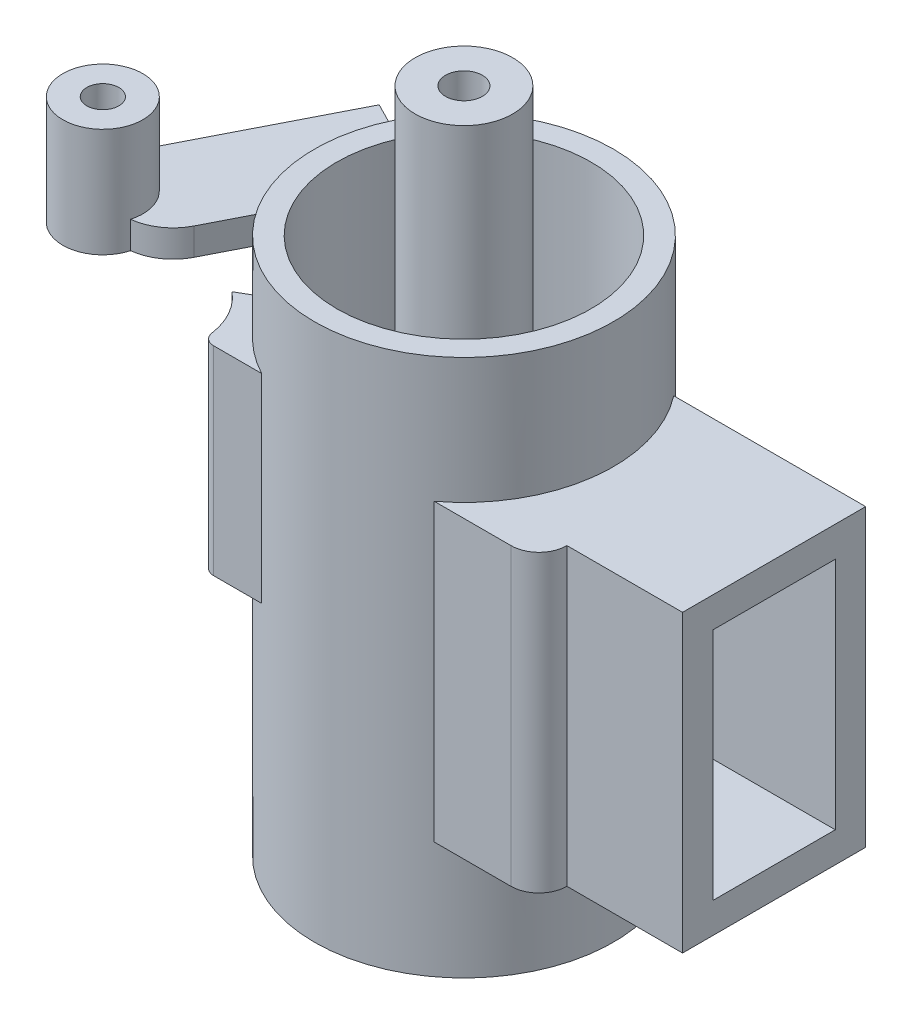
from build123d import *

# Parameters (mm, degrees)
SKETCH1_R            = 9.35
SKETCH1_R_2          = 7.95
BOSS_EXTRUDE1_DEPTH  = 31.6
SKETCH2_R            = 3.05
SKETCH2_R_2          = 1.15
BOSS_EXTRUDE2_DEPTH  = 45
BOSS_EXTRUDE3_DEPTH  = 18.45
SKETCH5_W            = 7.65
SKETCH5_H            = 14.65
CUT_EXTRUDE1_DEPTH   = 15
SKETCH6_R            = 7.95
SKETCH6_R_2          = 3.05
BOSS_EXTRUDE4_DEPTH  = 0.2
CUT_EXTRUDE4_DEPTH   = 0.2
BOSS_EXTRUDE5_DEPTH  = 7.45
BOSS_EXTRUDE6_DEPTH  = 1.7
BOSS_EXTRUDE7_START  = -1.7
SKETCH10_R           = 2.5
SKETCH10_R_2         = 1
BOSS_EXTRUDE7_DEPTH  = 7.7
BOSS_EXTRUDE8_DEPTH  = 1.7
BOSS_EXTRUDE9_DEPTH  = 5
SKETCH13_R           = 9.35
SKETCH13_R_2         = 7.95
BOSS_EXTRUDE12_DEPTH = 2
BOSS_EXTRUDE13_DEPTH = 1.7
CUT_EXTRUDE5_DEPTH   = 0.9
BOSS_EXTRUDE14_DEPTH = 0.9


with BuildPart() as part:
    # Sketch1 → Boss-Extrude1 (new body)
    with BuildSketch(Plane(origin=(0, 0, 0), x_dir=(1, 0, 0), z_dir=(0, 1, 0))):
        Circle(SKETCH1_R)
        Circle(SKETCH1_R_2, mode=Mode.SUBTRACT)
    extrude(amount=BOSS_EXTRUDE1_DEPTH)

    # Sketch4 → Boss-Extrude3 (add)
    with BuildSketch(Plane(origin=(0, 7.3, 0), x_dir=(1, 0, 0), z_dir=(0, 1, 0))):
        with BuildLine():
            Line((19.392352467, 5.725), (7.392352467, 5.725))
            ThreePointArc((7.392352467, 5.725), (9.266531417, -1.24655345), (5.616660485, -7.475))
            Line((5.616660485, -7.475), (10.416660485, -7.475))
            ThreePointArc((10.416660485, -7.475), (11.654097352, -6.962436867), (12.166660485, -5.725))
            Line((12.166660485, -5.725), (19.392352467, -5.725))
            Line((19.392352467, -5.725), (19.392352467, 5.725))
        make_face()
    extrude(amount=BOSS_EXTRUDE3_DEPTH)

    # Sketch5 → Cut-Extrude1 (cut)
    with BuildSketch(Plane(origin=(19.392352467, 0, 0), x_dir=(0, 0, -1), z_dir=(1, 0, 0))):
        with Locations((0, 16.525)):
            Rectangle(SKETCH5_W, SKETCH5_H)
    extrude(amount=-CUT_EXTRUDE1_DEPTH, mode=Mode.SUBTRACT)



with BuildPart() as body_2:
    # Sketch2 → Boss-Extrude2 (new body)
    with BuildSketch(Plane(origin=(0, -3.3, 0), x_dir=(1, 0, 0), z_dir=(0, 1, 0))):
        Circle(SKETCH2_R)
        Circle(SKETCH2_R_2, mode=Mode.SUBTRACT)
    extrude(amount=BOSS_EXTRUDE2_DEPTH)


with BuildPart() as part_1:
    add(part.part)

    add(body_2.part)  # Boss-Extrude4 merges body 2
    # Sketch6 → Boss-Extrude4 (add)
    with BuildSketch(Plane(origin=(0, 16, 0), x_dir=(1, 0, 0), z_dir=(0, 1, 0))):
        Circle(SKETCH6_R)
        Circle(SKETCH6_R_2, mode=Mode.SUBTRACT)
    extrude(amount=BOSS_EXTRUDE4_DEPTH)

    # Sketch7 → Cut-Extrude4 (cut)
    with BuildSketch(Plane(origin=(0, 16, 0), x_dir=(1, 0, 0), z_dir=(0, 1, 0))):
        with BuildLine():
            Line((6.969352552, 3.825), (1.069352552, 3.825))
            Line((1.069352552, 3.825), (1.069352552, 2.856393726))
            ThreePointArc((1.069352552, 2.856393726), (3.05, 0), (1.069352552, -2.856393726))
            Line((1.069352552, -2.856393726), (1.069352552, -3.825))
            Line((1.069352552, -3.825), (6.969352552, -3.825))
            ThreePointArc((6.969352552, -3.825), (7.95, 0), (6.969352552, 3.825))
        make_face()
    extrude(amount=CUT_EXTRUDE4_DEPTH, mode=Mode.SUBTRACT)

    # Sketch8 → Boss-Extrude5 (add)
    with BuildSketch(Plane(origin=(0, 20.6, 0), x_dir=(1, 0, 0), z_dir=(0, 1, 0))):
        with BuildLine():
            Line((-4.4, -8.25), (-7.403469592, -8.25))
            ThreePointArc((-7.403469592, -8.25), (-7.894744058, -8.066700449), (-8.145884154, -7.606398397))
            ThreePointArc((-8.145884154, -7.606398397), (-8.681216078, -6.028326508), (-9.750221455, -4.75))
            Line((-9.750221455, -4.75), (-8.451183349, -4))
            ThreePointArc((-8.451183349, -4), (-6.767854414, -6.451251555), (-4.4, -8.25))
        make_face()
    extrude(amount=BOSS_EXTRUDE5_DEPTH)

    # Sketch12 → Boss-Extrude9 (add)
    with BuildSketch(Plane.XZ.offset(-20.6)):
        with BuildLine():
            Line((-4.4, 8.25), (-7.403469592, 8.25))
            ThreePointArc((-7.403469592, 8.25), (-7.894744058, 8.066700449), (-8.145884154, 7.606398397))
            ThreePointArc((-8.145884154, 7.606398397), (-8.681216078, 6.028326508), (-9.750221455, 4.75))
            Line((-9.750221455, 4.75), (-8.451183349, 4))
            ThreePointArc((-8.451183349, 4), (-6.767854414, 6.451251555), (-4.4, 8.25))
        make_face()
    extrude(amount=BOSS_EXTRUDE9_DEPTH)



with BuildPart() as body_2_2:
    # Sketch9 → Boss-Extrude6 (new body)
    with BuildSketch(Plane(origin=(0, 31.6, 0), x_dir=(1, 0, 0), z_dir=(0, 1, 0))):
        with BuildLine():
            Line((-8.328265125, 4.25), (-10.822291045, 5.522727273))
            Line((-10.822291045, 5.522727273), (-17.029180659, -6.640242682))
            Line((-17.029180659, -6.640242682), (-14.089792968, -8.140242682))
            ThreePointArc((-14.089792968, -8.140242682), (-11.800883152, -8.321818546), (-10.053985976, -6.831708418))
            Line((-10.053985976, -6.831708418), (-8.526111367, -3.837697872))
            ThreePointArc((-8.526111367, -3.837697872), (-9.347203644, 0.228657047), (-8.328265125, 4.25))
        make_face()
    extrude(amount=-BOSS_EXTRUDE6_DEPTH)

    # Sketch10 → Boss-Extrude7 (add)
    with BuildSketch(Plane(origin=(0, 31.6, 0), x_dir=(1, 0, 0), z_dir=(0, 1, 0)).offset(BOSS_EXTRUDE7_START)):
        with Locations((-14.802371802, -7.776606319)):
            Circle(SKETCH10_R)
        with Locations((-14.802371802, -7.776606319)):
            Circle(SKETCH10_R_2, mode=Mode.SUBTRACT)
    extrude(amount=BOSS_EXTRUDE7_DEPTH)

    # Sketch11 → Boss-Extrude8 (add)
    with BuildSketch(Plane(origin=(0, 31.6, 0), x_dir=(1, 0, 0), z_dir=(0, 1, 0))):
        with BuildLine():
            Line((-15.693095345, -7.322060864), (-14.089792968, -8.140242682))
            ThreePointArc((-14.089792968, -8.140242682), (-13.999922503, -8.184231187), (-13.908635087, -8.225198209))
            ThreePointArc((-13.908635087, -8.225198209), (-15.253942988, -8.668841413), (-15.693095345, -7.322060864))
        make_face()
    extrude(amount=-BOSS_EXTRUDE8_DEPTH)


with BuildPart() as part_2:
    add(part_1.part)

    add(body_2_2.part)  # Boss-Extrude12 merges body 2 2
    # Sketch13 → Boss-Extrude12 (add)
    with BuildSketch(Plane(origin=(0, 31.6, 0), x_dir=(1, 0, 0), z_dir=(0, 1, 0))):
        Circle(SKETCH13_R)
        Circle(SKETCH13_R_2, mode=Mode.SUBTRACT)
    extrude(amount=BOSS_EXTRUDE12_DEPTH)

    # Sketch14 → Boss-Extrude13 (add)
    with BuildSketch(Plane(origin=(0, 31.6, 0), x_dir=(1, 0, 0), z_dir=(0, 1, 0))):
        with BuildLine():
            Line((-10.053985976, -6.831708418), (-8.526111367, -3.837697872))
            ThreePointArc((-8.526111367, -3.837697872), (-9.347203644, 0.228657047), (-8.328265125, 4.25))
            Line((-8.328265125, 4.25), (-10.822291045, 5.522727273))
            Line((-10.822291045, 5.522727273), (-17.029180659, -6.640242682))
            ThreePointArc((-17.029180659, -6.640242682), (-15.711611281, -10.105400764), (-12.394688357, -8.449703956))
            ThreePointArc((-12.394688357, -8.449703956), (-11.020302269, -7.935876946), (-10.053985976, -6.831708418))
        make_face()
    extrude(amount=-BOSS_EXTRUDE13_DEPTH)

    # Sketch15 → Cut-Extrude5 (cut)
    with BuildSketch(Plane.XZ.offset(-29.9)):
        with BuildLine():
            Line((-17.029180659, 6.640242682), (-10.822291045, -5.522727273))
            Line((-10.822291045, -5.522727273), (-8.328265125, -4.25))
            ThreePointArc((-8.328265125, -4.25), (-9.347203644, -0.228657047), (-8.526111367, 3.837697872))
            Line((-8.526111367, 3.837697872), (-10.053985976, 6.831708418))
            ThreePointArc((-10.053985976, 6.831708418), (-11.020302269, 7.935876946), (-12.394688357, 8.449703956))
            ThreePointArc((-12.394688357, 8.449703956), (-15.711611281, 10.105400764), (-17.029180659, 6.640242682))
        make_face()
    extrude(amount=-CUT_EXTRUDE5_DEPTH, mode=Mode.SUBTRACT)

    # Sketch17 → Boss-Extrude14 (add)
    with BuildSketch(Plane(origin=(0, 31.6, 0), x_dir=(1, 0, 0), z_dir=(0, 1, 0))):
        with BuildLine():
            Line((-10.053985976, -6.831708418), (-8.526111367, -3.837697872))
            ThreePointArc((-8.526111367, -3.837697872), (-9.347203644, 0.228657047), (-8.328265125, 4.25))
            Line((-8.328265125, 4.25), (-10.822291045, 5.522727273))
            Line((-10.822291045, 5.522727273), (-17.029180659, -6.640242682))
            ThreePointArc((-17.029180659, -6.640242682), (-15.711611281, -10.105400764), (-12.394688357, -8.449703956))
            ThreePointArc((-12.394688357, -8.449703956), (-11.020302269, -7.935876946), (-10.053985976, -6.831708418))
        make_face()
    extrude(amount=BOSS_EXTRUDE14_DEPTH)


solid = part_2.part
